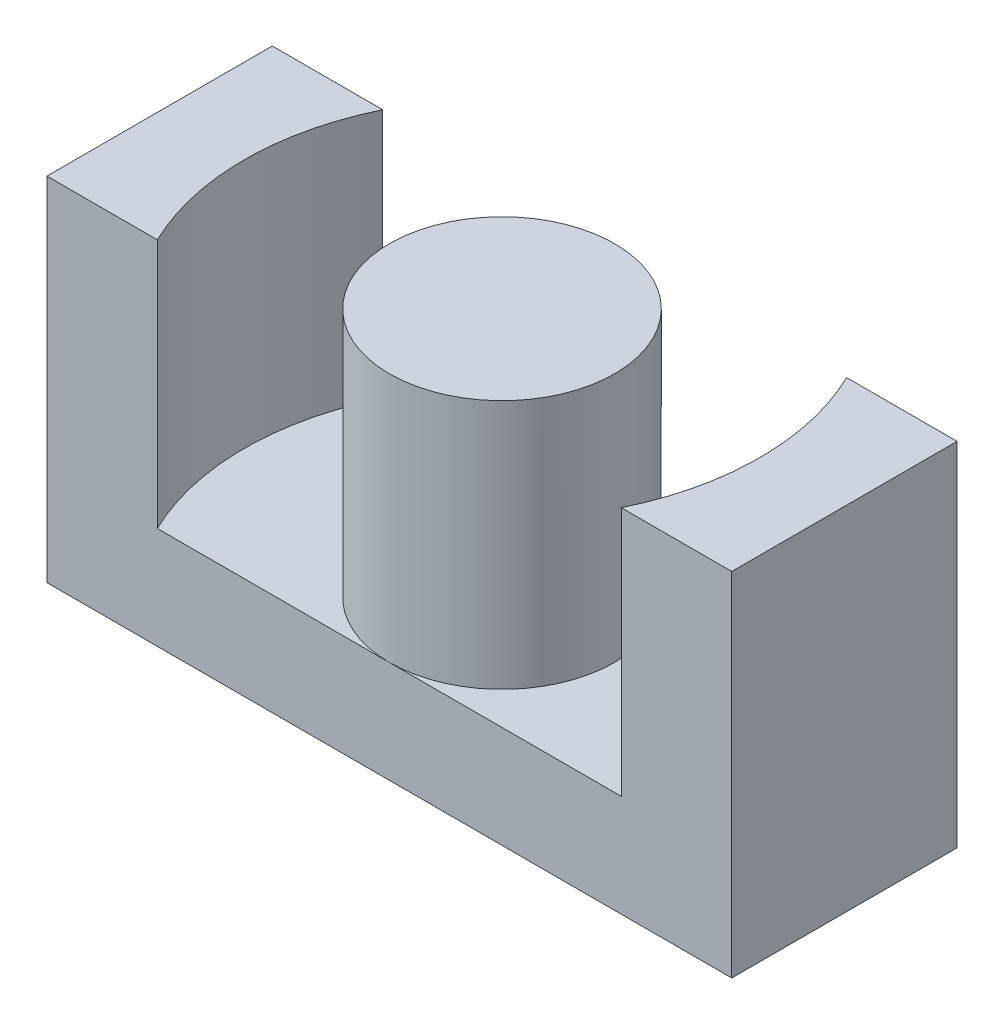
from build123d import *

# Parameters (mm, degrees)
SKETCH2_W           = 38.9
SKETCH2_H           = 12.8
BOSS_EXTRUDE1_DEPTH = 5.8
SKETCH3_R           = 6.4
BOSS_EXTRUDE2_DEPTH = 14.2


with BuildPart() as part:
    # Sketch2 → Boss-Extrude1 (new body)
    with BuildSketch(Plane(origin=(0, 0, 0), x_dir=(1, 0, 0), z_dir=(0, 1, 0))):
        Rectangle(SKETCH2_W, SKETCH2_H)
    extrude(amount=BOSS_EXTRUDE1_DEPTH)

    # Sketch3 → Boss-Extrude2 (add)
    with BuildSketch(Plane(origin=(0, 5.8, 0), x_dir=(1, 0, 0), z_dir=(0, 1, 0))):
        with BuildLine():
            Line((-13.178106844, 6.4), (-19.45, 6.4))
            Line((-19.45, 6.4), (-19.45, -6.4))
            Line((-19.45, -6.4), (-13.178106844, -6.4))
            ThreePointArc((-13.178106844, -6.4), (-14.65, 0), (-13.178106844, 6.4))
        make_face()
        Circle(SKETCH3_R)
        with BuildLine():
            Line((19.45, 6.4), (13.178106844, 6.4))
            ThreePointArc((13.178106844, 6.4), (14.65, 0), (13.178106844, -6.4))
            Line((13.178106844, -6.4), (19.45, -6.4))
            Line((19.45, -6.4), (19.45, 6.4))
        make_face()
    extrude(amount=BOSS_EXTRUDE2_DEPTH)


solid = part.part
